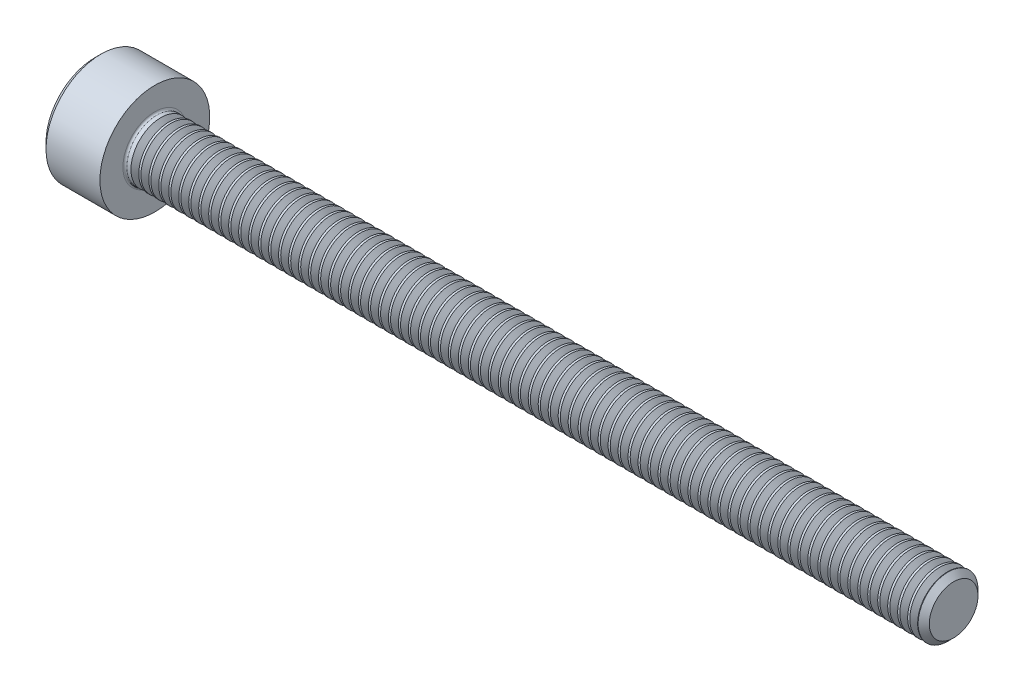
from build123d import *

# Parameters (mm, degrees)
FILLET1_R       = 0.1
HEX_2_DEPTH     = 1.3
THDSCHPAT_COUNT = 79
THDSCHPAT_PITCH = 0.5


with BuildPart() as part:
    # BodySke → Base-Revolve (revolve)
    with BuildSketch(Plane.XY):
        Polygon((0, 0), (0, 2.45), (0.3, 2.75), (3, 2.75), (3, 1.5), (42.7195, 1.5), (43, 1.2195), (43, 0), align=None)
    revolve(axis=Axis((-31.75, 0, 0), (1, 0, 0)))

    # Fillet1
    fillet1_edges = [part.edges().sort_by_distance(p)[0] for p in [
        (3, -1.5, 0),
    ]]
    fillet(fillet1_edges, radius=FILLET1_R)

    # Sketch2 → Hex-PreBroach (revolve, cut)
    with BuildSketch(Plane.XY):
        Polygon((0, 1.28), (1.3, 1.28), (2.039008345, 0), (0, 0), align=None)
    revolve(axis=Axis((0, 0, 0), (1, 0, 0)), mode=Mode.SUBTRACT)

    # Sketch3 → Hex 2 (cut)
    with BuildSketch(Plane(origin=(0, 0, 0), x_dir=(0, 0.5, 0.866025404), z_dir=(-1, 0, 0))):
        Polygon((0.739008345, 1.28), (-0.739008345, 1.28), (-1.478016689, 0), (-0.739008345, -1.28), (0.739008345, -1.28), (1.478016689, 0), align=None)
    extrude(amount=-HEX_2_DEPTH, mode=Mode.SUBTRACT)

    # ThdSchSke → ThreadSchematic (revolve, cut)
    with BuildSketch(Plane.XY):
        Polygon((3.5, -1.2195), (3.303591786, -1.5), (3.303591786, -1.875), (3.696408214, -1.875), (3.696408214, -1.5), align=None)
    threadschematic = revolve(axis=Axis((-3.175, 0, 0), (1, 0, 0)), mode=Mode.SUBTRACT)

    # ThdSchPat: ThreadSchematic ×79
    with Locations(*[(i * THDSCHPAT_PITCH, 0, 0) for i in range(1, THDSCHPAT_COUNT)]):
        add(threadschematic, mode=Mode.SUBTRACT)


solid = part.part
